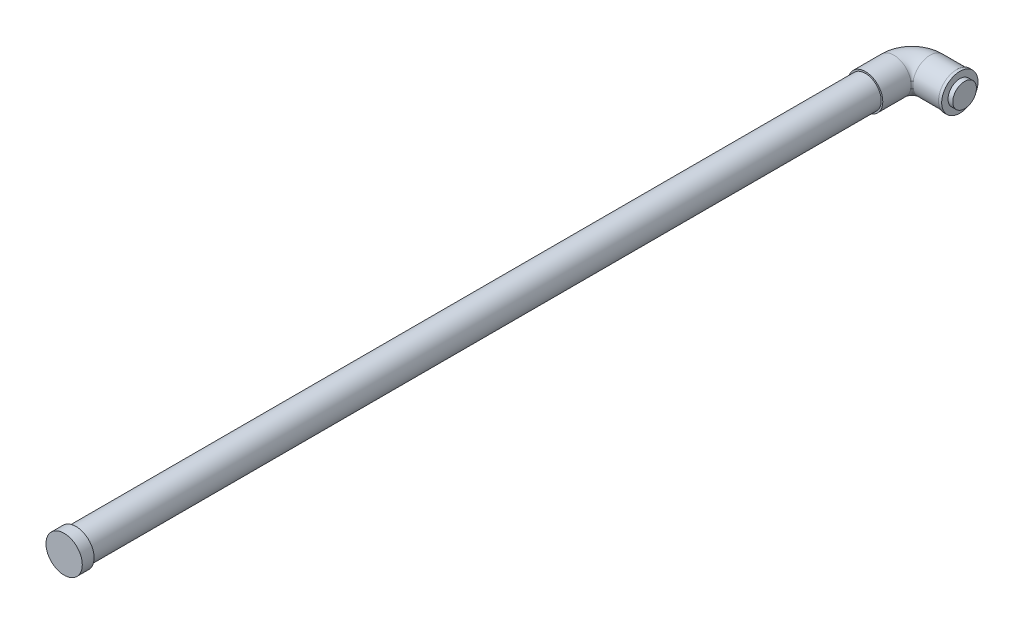
from build123d import *

# Parameters (mm, degrees)
SWEEP1_PROFILE_R    = 11
SKETCH34_R          = 11
BOSS_EXTRUDE1_DEPTH = 7.5
SKETCH41_R          = 11.5
BOSS_EXTRUDE2_DEPTH = 2
SKETCH42_R          = 10
BOSS_EXTRUDE3_DEPTH = 500
SKETCH43_R          = 11.5
BOSS_EXTRUDE4_DEPTH = 7.5
SKETCH129_R         = 7.5
BOSS_EXTRUDE5_DEPTH = 3


with BuildPart() as part:
    # Sweep1: sweep along a path in Sketch1
    with BuildLine(Plane(origin=(0, 0, 0), x_dir=(1, 0, 0), z_dir=(0, 1, 0))) as sweep1_path:
        Line((-112.299146126, 73.980831747), (-112.299146126, 84.480831747))
        ThreePointArc((-112.299146126, 84.480831747), (-108.93087411, 92.612559731), (-100.799146126, 95.980831747))
        Line((-100.799146126, 95.980831747), (-83.999146126, 95.980831747))
    # Sweep1 profile (on start of the path) → Sweep1 (sweep)
    with BuildSketch(Plane(origin=(-112.299146126, 0, -73.980831747), x_dir=(-1, 0, 0), z_dir=(0, 0, -1))):
        Circle(SWEEP1_PROFILE_R)
    sweep(path=sweep1_path.line)

    # Sketch34 → Boss-Extrude1 (add)
    with BuildSketch(Plane.XY.offset(-73.980831747)):
        with Locations((-112.299146126, 0)):
            Circle(SKETCH34_R)
    extrude(amount=BOSS_EXTRUDE1_DEPTH)

    # Sketch41 → Boss-Extrude2 (add)
    with BuildSketch(Plane(origin=(-83.999146126, 0, 0), x_dir=(0, 0, -1), z_dir=(1, 0, 0))):
        with Locations((95.980831747, 0)):
            Circle(SKETCH41_R)
    extrude(amount=BOSS_EXTRUDE2_DEPTH)

    # Sketch42 → Boss-Extrude3 (add)
    with BuildSketch(Plane.XY.offset(-66.480831747)):
        with Locations((-112.299146126, 0)):
            Circle(SKETCH42_R)
    extrude(amount=BOSS_EXTRUDE3_DEPTH)

    # Sketch43 → Boss-Extrude4 (add)
    with BuildSketch(Plane.XY.offset(433.519168253)):
        with Locations((-112.299146126, 0)):
            Circle(SKETCH43_R)
    extrude(amount=BOSS_EXTRUDE4_DEPTH)

    # Sketch129 → Boss-Extrude5 (add)
    with BuildSketch(Plane(origin=(-81.999146126, 0, 0), x_dir=(0, 0, -1), z_dir=(1, 0, 0))):
        with Locations((95.980831747, 0)):
            Circle(SKETCH129_R)
    extrude(amount=BOSS_EXTRUDE5_DEPTH)


solid = part.part
